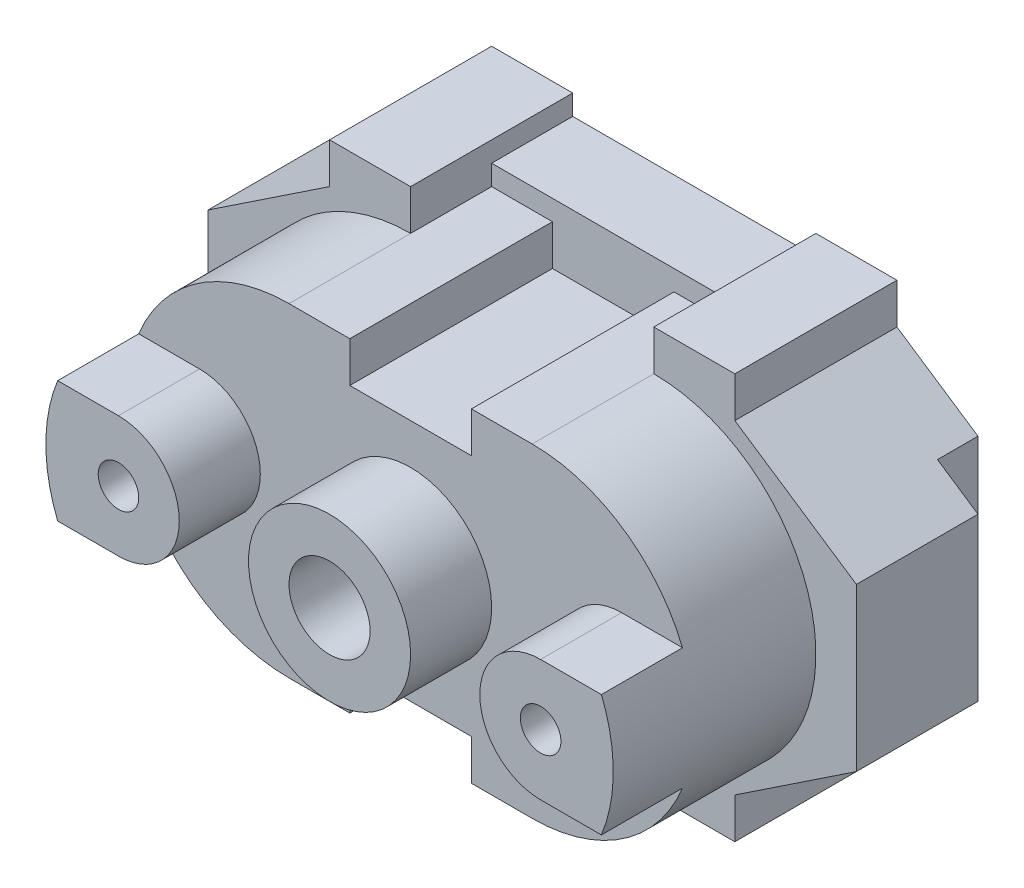
from build123d import *

# Parameters (mm, degrees)
BOSS_EXTRUDE1_DEPTH = 20
SKETCH2_W           = 5
SKETCH2_H           = 27.5
CUT_EXTRUDE2_DEPTH  = 5
SKETCH3_W           = 5
SKETCH3_H           = 27.5
CUT_EXTRUDE3_DEPTH  = 5
BOSS_EXTRUDE2_DEPTH = 15
SKETCH5_W           = 30
SKETCH5_H           = 2.5
BOSS_EXTRUDE3_DEPTH = 10
SKETCH6_W           = 15
SKETCH6_H           = 5
CUT_EXTRUDE4_DEPTH  = 25
SKETCH7_R           = 10
BOSS_EXTRUDE4_DEPTH = 10
SKETCH8_R           = 5
CUT_EXTRUDE5_DEPTH  = 310
BOSS_EXTRUDE5_DEPTH = 10
SKETCH11_R          = 2.5
CUT_EXTRUDE6_DEPTH  = 300


with BuildPart() as part:
    # Sketch1 → Boss-Extrude1 (new body)
    with BuildSketch(Plane.XY):
        Polygon((-80, 0), (-65, 10), (-65, 15), (-55, 15), (-55, 10), (-25, 10), (-25, 15), (-15, 15), (-15, 10), (0, 0), (0, -20), (-15, -30), (-15, -35), (-25, -35), (-25, -30), (-55, -30), (-55, -35), (-65, -35), (-65, -30), (-80, -20), align=None)
    extrude(amount=BOSS_EXTRUDE1_DEPTH)

    # Sketch2 → Cut-Extrude2 (cut)
    with BuildSketch(Plane.ZY.offset(80)):
        with Locations((2.5, -10)):
            Rectangle(SKETCH2_W, SKETCH2_H)
    extrude(amount=-CUT_EXTRUDE2_DEPTH, mode=Mode.SUBTRACT)

    # Sketch3 → Cut-Extrude3 (cut)
    with BuildSketch(Plane(origin=(0, 0, 0), x_dir=(0, 0, -1), z_dir=(1, 0, 0))):
        with Locations((-2.5, -10)):
            Rectangle(SKETCH3_W, SKETCH3_H)
    extrude(amount=-CUT_EXTRUDE3_DEPTH, mode=Mode.SUBTRACT)

    # Sketch4 → Boss-Extrude2 (add)
    with BuildSketch(Plane.XY.offset(20)):
        with BuildLine():
            Line((-55, 10), (-25, 10))
            ThreePointArc((-25, 10), (-5, -10), (-25, -30))
            Line((-25, -30), (-55, -30))
            ThreePointArc((-55, -30), (-75, -10), (-55, 10))
        make_face()
    extrude(amount=BOSS_EXTRUDE2_DEPTH)

    # Sketch5 → Boss-Extrude3 (add)
    with BuildSketch(Plane(origin=(0, 0, 0), x_dir=(-1, 0, 0), z_dir=(0, 0, -1))):
        with Locations((40, -31.25)):
            Rectangle(SKETCH5_W, SKETCH5_H)
        with Locations((40, 11.25)):
            Rectangle(SKETCH5_W, SKETCH5_H)
    extrude(amount=-BOSS_EXTRUDE3_DEPTH)

    # Sketch6 → Cut-Extrude4 (cut)
    with BuildSketch(Plane.XY.offset(35)):
        with Locations((-40, -27.5)):
            Rectangle(SKETCH6_W, SKETCH6_H)
        with Locations((-40, 7.5)):
            Rectangle(SKETCH6_W, SKETCH6_H)
    extrude(amount=-CUT_EXTRUDE4_DEPTH, mode=Mode.SUBTRACT)

    # Sketch7 → Boss-Extrude4 (add)
    with BuildSketch(Plane.XY.offset(35)):
        with Locations((-40, -10)):
            Circle(SKETCH7_R)
    extrude(amount=BOSS_EXTRUDE4_DEPTH)

    # Sketch8 → Cut-Extrude5 (cut)
    with BuildSketch(Plane.XY.offset(45)):
        with Locations((-40, -10)):
            Circle(SKETCH8_R)
    extrude(amount=-CUT_EXTRUDE5_DEPTH, mode=Mode.SUBTRACT)

    # Sketch10 → Boss-Extrude5 (add)
    with BuildSketch(Plane.XY.offset(35)):
        with BuildLine():
            Line((-73.540496218, -17.5), (-66.040496218, -17.5))
            ThreePointArc((-66.040496218, -17.5), (-58.540496218, -10), (-66.040496218, -2.5))
            Line((-66.040496218, -2.5), (-73.540496218, -2.5))
            ThreePointArc((-73.540496218, -2.5), (-75, -10), (-73.540496218, -17.5))
        make_face()
        with BuildLine():
            Line((-6.459503782, -17.5), (-13.959503782, -17.5))
            ThreePointArc((-13.959503782, -17.5), (-21.459503782, -10), (-13.959503782, -2.5))
            Line((-13.959503782, -2.5), (-6.459503782, -2.5))
            ThreePointArc((-6.459503782, -2.5), (-5, -10), (-6.459503782, -17.5))
        make_face()
    extrude(amount=BOSS_EXTRUDE5_DEPTH)

    # Sketch11 → Cut-Extrude6 (cut)
    with BuildSketch(Plane.XY.offset(45)):
        with Locations((-66.040496218, -10)):
            Circle(SKETCH11_R)
        with Locations((-13.959503782, -10)):
            Circle(SKETCH11_R)
    extrude(amount=-CUT_EXTRUDE6_DEPTH, mode=Mode.SUBTRACT)


solid = part.part
